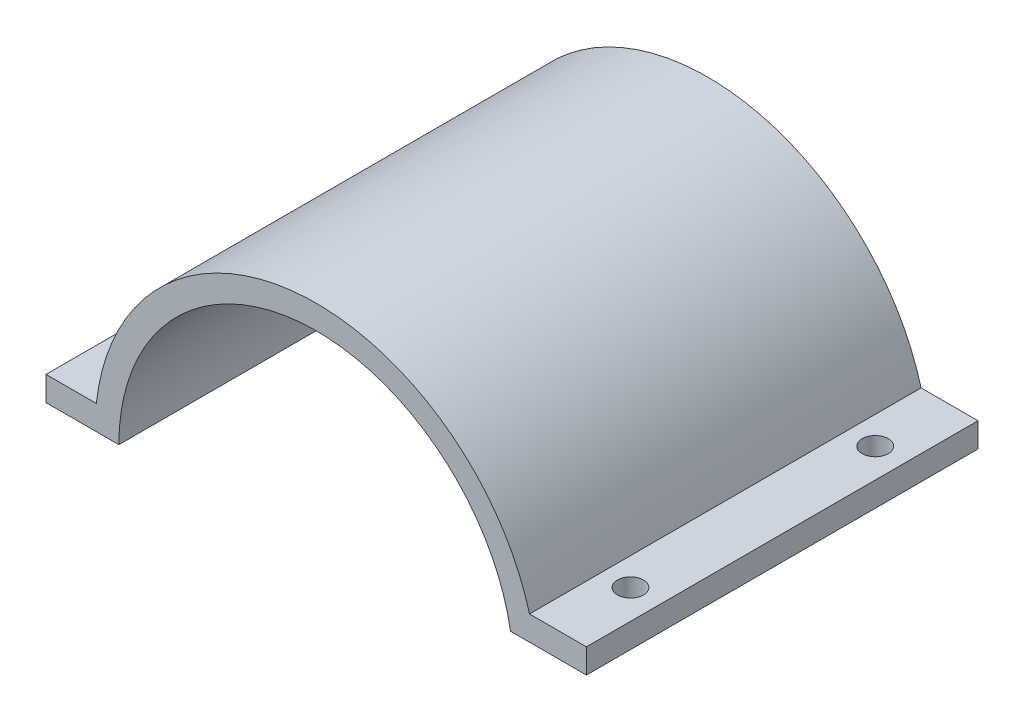
from build123d import *

# Parameters (mm, degrees)
BOSS_EXTRUDE1_DEPTH     = 50.8
F_1_4_CLEARANCE_HOLE1_D = 6.7564
F_1_4_CLEARANCE_HOLE2_D = 6.7564


with BuildPart() as part:
    # Sketch1 → Boss-Extrude1 (new body, symmetric)
    with BuildSketch(Plane.XY):
        with BuildLine():
            Line((-57.051702131, 6.35), (-70.104, 6.35))
            Line((-70.104, 6.35), (-70.104, 0))
            Line((-70.104, 0), (-51.203999954, 0))
            ThreePointArc((-51.203999954, 0), (-4.462722648, 51.009153275), (50.42609614, 8.891481281))
            Line((50.42609614, 8.891481281), (70.104, 8.891481281))
            Line((70.104, 8.891481281), (70.104, 15.241481281))
            Line((70.104, 15.241481281), (55.343621713, 15.241481281))
            ThreePointArc((55.343621713, 15.241481281), (-4.527029326, 57.22521491), (-57.051702131, 6.35))
        make_face()
    extrude(amount=BOSS_EXTRUDE1_DEPTH, both=True)

    # 1/4 Clearance Hole1 (through all)
    with Locations(Plane(origin=(0, 6.35, 0), x_dir=(1, 0, 0), z_dir=(0, 1, 0))):
        with Locations((-62.484, -31.75), (-62.484, 31.75)):
            Hole(F_1_4_CLEARANCE_HOLE1_D / 2)

    # 1/4 Clearance Hole2 (through all)
    with Locations(Plane(origin=(0, 15.241481281, 0), x_dir=(1, 0, 0), z_dir=(0, 1, 0))):
        with Locations((62.484, -31.75), (62.484, 31.75)):
            Hole(F_1_4_CLEARANCE_HOLE2_D / 2)


solid = part.part
